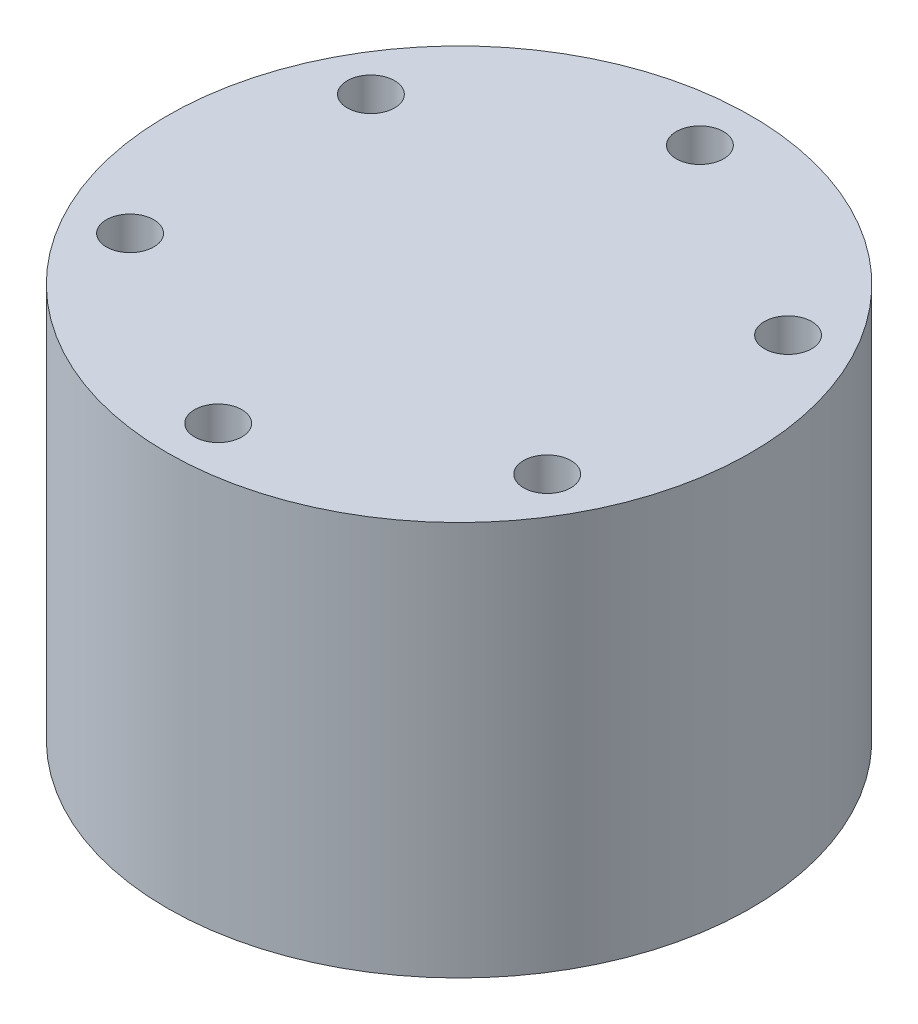
from build123d import *

# Parameters (mm, degrees)
SKETCH1_R           = 18.5
BOSS_EXTRUDE1_DEPTH = 25
SKETCH2_R           = 1.5
CUT_EXTRUDE1_DEPTH  = 10


with BuildPart() as part:
    # Sketch1 → Boss-Extrude1 (new body)
    with BuildSketch(Plane(origin=(0, 0, 0), x_dir=(1, 0, 0), z_dir=(0, 1, 0))):
        Circle(SKETCH1_R)
    extrude(amount=BOSS_EXTRUDE1_DEPTH)

    # Sketch2 → Cut-Extrude1 (cut)
    with BuildSketch(Plane(origin=(0, 25, 0), x_dir=(1, 0, 0), z_dir=(0, 1, 0))):
        with Locations((0, 15.265)):
            Circle(SKETCH2_R)
        with Locations((13.219877789, 7.6325)):
            Circle(SKETCH2_R)
        with Locations((13.219877789, -7.6325)):
            Circle(SKETCH2_R)
        with Locations((0, -15.265)):
            Circle(SKETCH2_R)
        with Locations((-13.219877789, -7.6325)):
            Circle(SKETCH2_R)
        with Locations((-13.219877789, 7.6325)):
            Circle(SKETCH2_R)
    extrude(amount=-CUT_EXTRUDE1_DEPTH, mode=Mode.SUBTRACT)


solid = part.part
